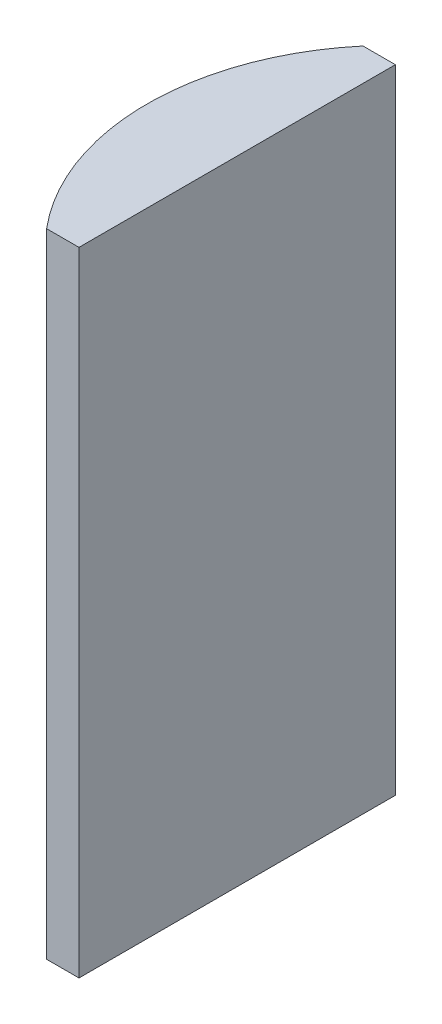
from build123d import *

# Parameters (mm, degrees)
EXTRUDE_1_DEPTH = 40


with BuildPart() as part:
    # 草图1 → 凸台-拉伸1 (new body)
    with BuildSketch(Plane(origin=(0, 0, 0), x_dir=(1, 0, 0), z_dir=(0, 1, 0))):
        with BuildLine():
            Line((-7.500600151, 10), (-5.454795665, 10))
            Line((-5.454795665, 10), (-5.454795665, -10))
            Line((-5.454795665, -10), (-7.500600151, -10))
            ThreePointArc((-7.500600151, -10), (-11.154795665, 0), (-7.500600151, 10))
        make_face()
    extrude(amount=EXTRUDE_1_DEPTH)


solid = part.part
